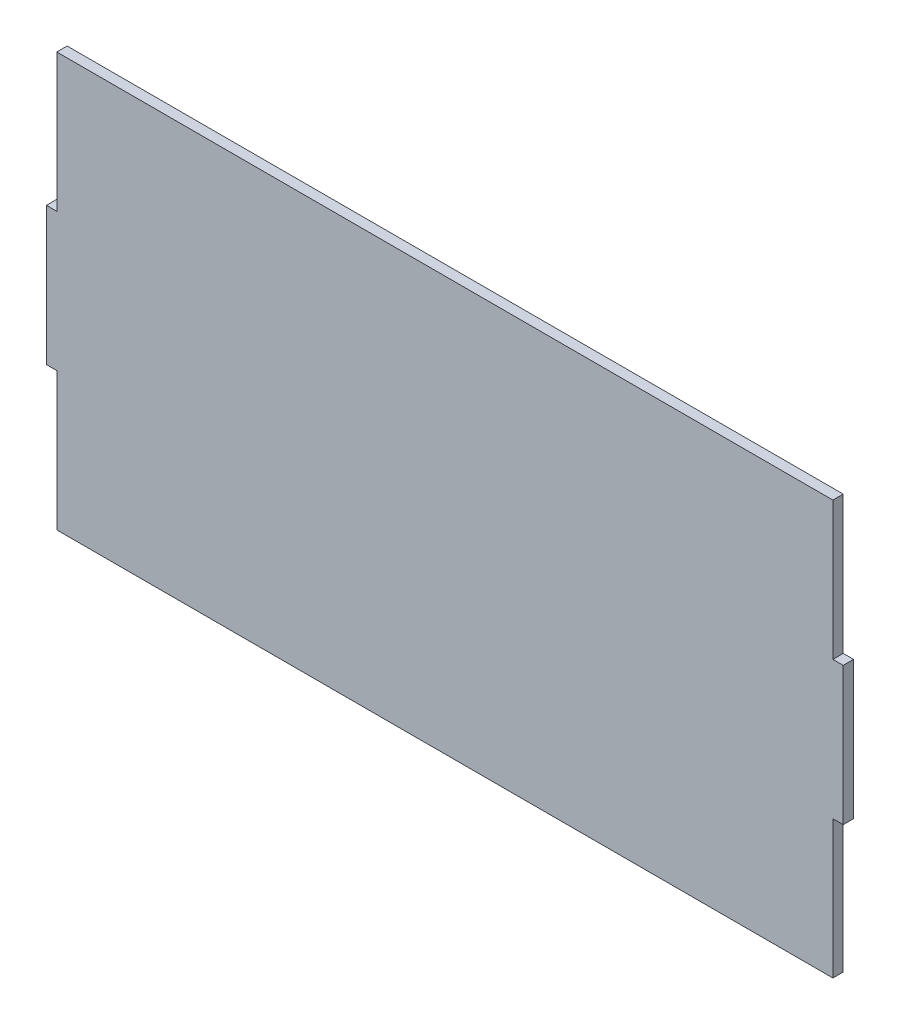
from build123d import *

# Parameters (mm, degrees)
BOSS_EXTRUDE1_DEPTH = 3


with BuildPart() as part:
    # Sketch1 → Boss-Extrude1 (new body)
    with BuildSketch(Plane.XY):
        Polygon((-112.5, 20), (-115.5, 20), (-115.5, -20), (-112.5, -20), (-112.5, -60), (112.5, -60), (112.5, -20), (115.5, -20), (115.5, 20), (112.5, 20), (112.5, 60), (-112.5, 60), align=None)
    extrude(amount=BOSS_EXTRUDE1_DEPTH)


solid = part.part
